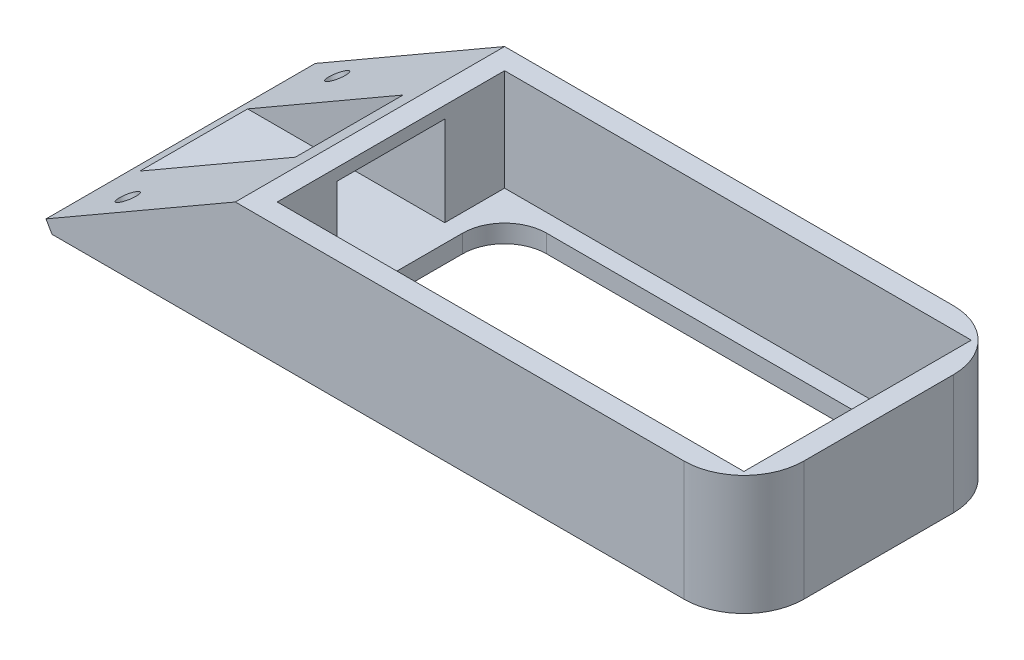
from build123d import *

# Parameters (mm, degrees)
BOSS_EXTRUDE1_DEPTH = 45
SKETCH2_W           = 78
SKETCH2_H           = 38
CUT_EXTRUDE1_DEPTH  = 17
CUT_EXTRUDE2_REACH  = 130.949
SKETCH3_W           = 72
SKETCH3_H           = 32
FILLET1_R           = 10
FILLET2_R           = 7
CUT_EXTRUDE3_REACH  = 97.222
SKETCH4_W           = 18
SKETCH4_H           = 15
CUT_EXTRUDE4_REACH  = 131.379
SKETCH5_R           = 1.6


with BuildPart() as part:
    # Sketch1 → Boss-Extrude1 (new body)
    with BuildSketch(Plane.XY):
        Polygon((34.641016151, 20), (3, 1.732050808), (4, 0), (119.641016151, 0), (119.641016151, 20), align=None)
    extrude(amount=BOSS_EXTRUDE1_DEPTH)

    # Sketch2 → Cut-Extrude1 (cut)
    with BuildSketch(Plane(origin=(0, 20, 0), x_dir=(1, 0, 0), z_dir=(0, 1, 0))):
        with Locations((77.141016151, -22.5)):
            Rectangle(SKETCH2_W, SKETCH2_H)
    extrude(amount=-CUT_EXTRUDE1_DEPTH, mode=Mode.SUBTRACT)

    # Sketch3 → Cut-Extrude2 (cut, up to next)
    with BuildSketch(Plane(origin=(0, 3, 0), x_dir=(1, 0, 0), z_dir=(0, 1, 0)), mode=Mode.PRIVATE) as cut_extrude2_sk1:
        with Locations((77.141016151, -22.5)):
            Rectangle(SKETCH3_W, SKETCH3_H)
    cut_extrude2_tool1 = extrude(cut_extrude2_sk1.sketch, amount=-CUT_EXTRUDE2_REACH, mode=Mode.PRIVATE) & part.part
    add(cut_extrude2_tool1.solids().sort_by_distance((77.141016, 3, 22.5))[0], mode=Mode.SUBTRACT)

    # Fillet1
    fillet1_edges = [part.edges().sort_by_distance(p)[0] for p in [
        (119.641016151, 10, 45),
        (119.641016151, 10, 0),
    ]]
    fillet(fillet1_edges, radius=FILLET1_R)

    # Fillet2
    fillet2_edges = [part.edges().sort_by_distance(p)[0] for p in [
        (41.141016151, 1.5, 38.5),
        (41.141016151, 1.5, 6.5),
        (113.141016151, 1.5, 6.5),
        (113.141016151, 1.5, 38.5),
    ]]
    fillet(fillet2_edges, radius=FILLET2_R)

    # Cut-Extrude3: up to this plane
    cut_extrude3_end = Plane(origin=(0, 0, 45), z_dir=(-0.5000000000000014, 0.8660254037844379, 0))
    # Sketch4 → Cut-Extrude3 (cut, up to the surface)
    with BuildSketch(Plane(origin=(38.141016151, 0, 0), x_dir=(0, 0, -1), z_dir=(1, 0, 0)), mode=Mode.PRIVATE) as cut_extrude3_sk1:
        with Locations((-22.5, 10.5)):
            Rectangle(SKETCH4_W, SKETCH4_H)
    cut_extrude3_tool1 = split(extrude(cut_extrude3_sk1.sketch, amount=-CUT_EXTRUDE3_REACH, mode=Mode.PRIVATE), bisect_by=cut_extrude3_end, keep=Keep.BOTH, mode=Mode.PRIVATE)
    add(cut_extrude3_tool1.solids().sort_by_distance((38.141016, 10.5, 22.5))[0], mode=Mode.SUBTRACT)

    # Cut-Extrude4: up to this plane
    cut_extrude4_end = Plane(origin=(0, 2, 45), z_dir=(0, 1, 0))
    # Sketch5 → Cut-Extrude4 (cut, up to the surface)
    with BuildSketch(Plane(origin=(0, 0, 0), x_dir=(0.8660254037844378, 0.5000000000000017, 0), z_dir=(-0.5000000000000016, 0.8660254037844377, 0)), mode=Mode.PRIVATE) as cut_extrude4_sk1:
        with Locations(Location((13.464101615, -5, 0), (0, 0, 180))):
            Circle(SKETCH5_R)
    cut_extrude4_tool1 = split(extrude(cut_extrude4_sk1.sketch, amount=-CUT_EXTRUDE4_REACH, mode=Mode.PRIVATE), bisect_by=cut_extrude4_end, keep=Keep.BOTH, mode=Mode.PRIVATE)
    add(cut_extrude4_tool1.solids().sort_by_distance((11.660254, 6.732051, 5))[0], mode=Mode.SUBTRACT)
    # Sketch5 → Cut-Extrude4 (cut, up to the surface)
    with BuildSketch(Plane(origin=(0, 0, 0), x_dir=(0.8660254037844378, 0.5000000000000017, 0), z_dir=(-0.5000000000000016, 0.8660254037844377, 0)), mode=Mode.PRIVATE) as cut_extrude4_sk2:
        with Locations(Location((13.464101615, -40, 0), (0, 0, 180))):
            Circle(SKETCH5_R)
    cut_extrude4_tool2 = split(extrude(cut_extrude4_sk2.sketch, amount=-CUT_EXTRUDE4_REACH, mode=Mode.PRIVATE), bisect_by=cut_extrude4_end, keep=Keep.BOTH, mode=Mode.PRIVATE)
    add(cut_extrude4_tool2.solids().sort_by_distance((11.660254, 6.732051, 40))[0], mode=Mode.SUBTRACT)


solid = part.part
